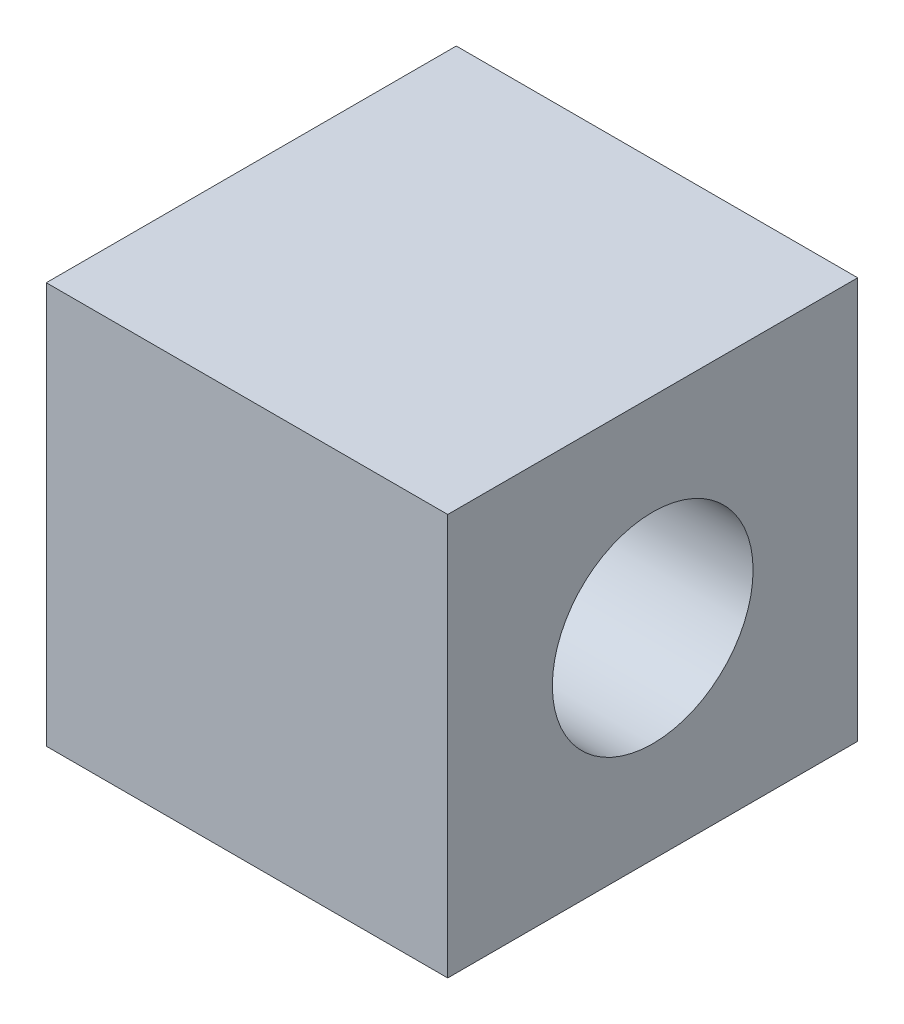
from build123d import *

# Parameters (mm, degrees)
SKETCH_1_W      = 10.212924232
SKETCH_1_H      = 10
SKETCH_1_R      = 2.5
EXTRUDE_1_DEPTH = 10


with BuildPart() as part:
    # 草图1 → 凸台-拉伸1 (new body)
    with BuildSketch(Plane(origin=(0, 0, 0), x_dir=(0, 0, -1), z_dir=(1, 0, 0))):
        Rectangle(SKETCH_1_W, SKETCH_1_H)
        Circle(SKETCH_1_R, mode=Mode.SUBTRACT)
    extrude(amount=EXTRUDE_1_DEPTH)


solid = part.part
